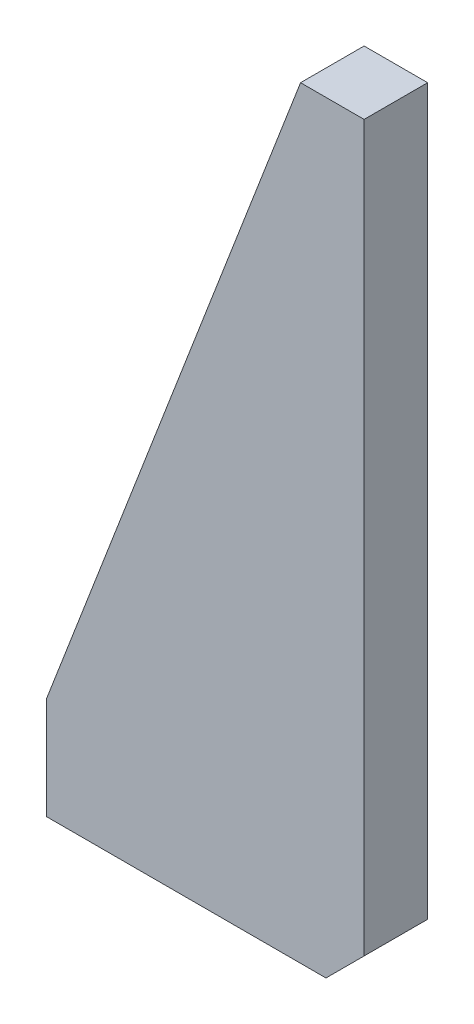
from build123d import *

# Parameters (mm, degrees)
EXTRUDE_1_DEPTH = 12.5
CHAMFER_1_SIZE  = 15


with BuildPart() as part:
    # Эскиз1 → Бобышка-Вытянуть1 (new body, symmetric)
    with BuildSketch(Plane.XY):
        Polygon((0, 300), (-25, 300), (-125, 40), (-125, 0), (0, 0), align=None)
    extrude(amount=EXTRUDE_1_DEPTH, both=True)

    # Фаска1
    chamfer_1_edges = [part.edges().sort_by_distance(p)[0] for p in [
        (0, 0, 0),
    ]]
    chamfer(chamfer_1_edges, length=CHAMFER_1_SIZE)


solid = part.part
